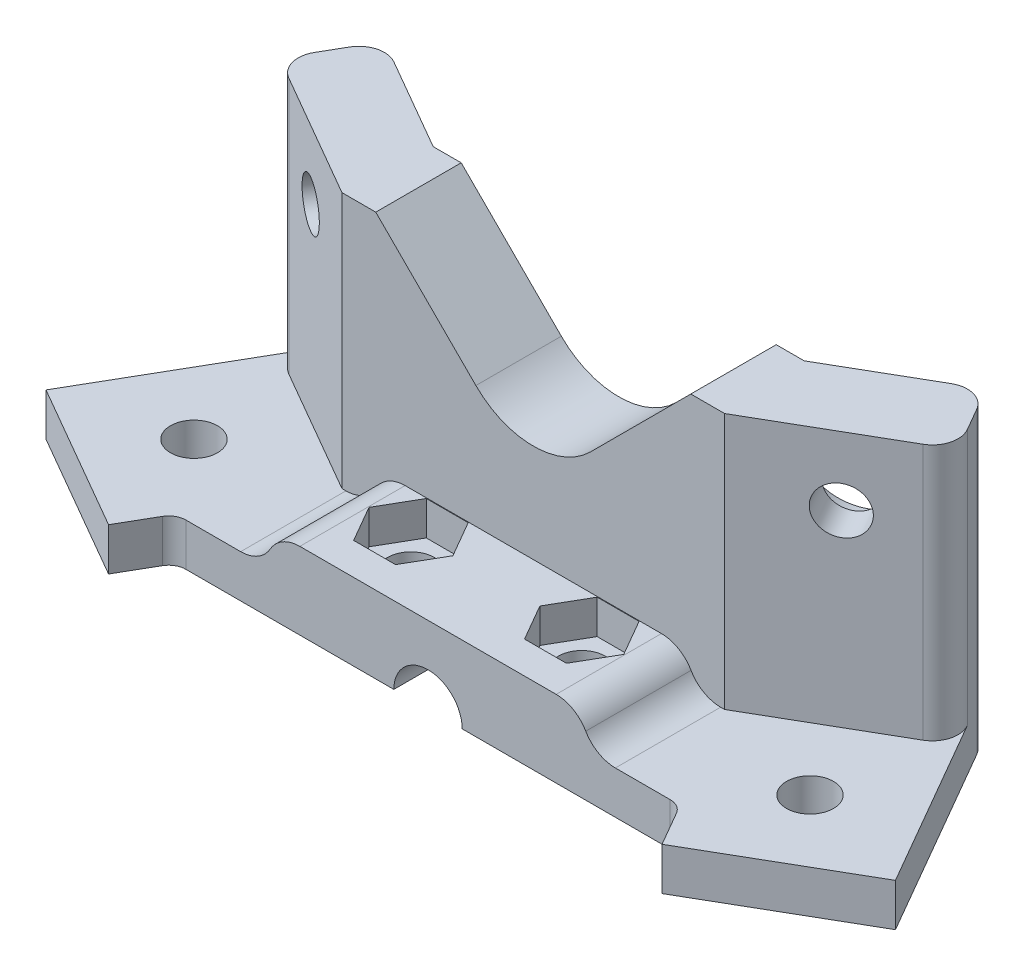
from build123d import *

# Parameters (mm, degrees)
SKETCH1_R                = 2.75
BOSS_EXTRUDE1_DEPTH      = 5
BOSS_EXTRUDE2_DEPTH      = 30
BOSS_EXTRUDE2_DEPTH_BACK = 5
BOSS_EXTRUDE3_DEPTH      = 12.320508
SKETCH5_R                = 4
CUT_EXTRUDE1_DEPTH       = 28.320508076
SKETCH7_R                = 2.75
CUT_EXTRUDE3_DEPTH       = 51.510942144
CUT_EXTRUDE4_START       = -4
SKETCH8_R                = 6
CUT_EXTRUDE4_DEPTH       = 47.510942144
SKETCH9_R                = 2.75
CUT_EXTRUDE5_DEPTH       = 10
CUT_EXTRUDE6_DEPTH       = 4
FILLET2_R                = 3


with BuildPart() as part:
    # Sketch1 → Boss-Extrude1 (new body)
    with BuildSketch(Plane(origin=(0, 0, 0), x_dir=(1, 0, 0), z_dir=(0, 1, 0))):
        with BuildLine():
            Line((-39.711904038, 0), (39.711904038, 0))
            Line((39.711904038, 0), (49.711904038, -17.320508076))
            Line((49.711904038, -17.320508076), (32.391395962, -27.320508076))
            Line((32.391395962, -27.320508076), (30.081994885, -23.320508076))
            ThreePointArc((30.081994885, -23.320508076), (29.349944078, -22.588457268), (28.349944078, -22.320508076))
            Line((28.349944078, -22.320508076), (-28.349944078, -22.320508076))
            ThreePointArc((-28.349944078, -22.320508076), (-29.349944078, -22.588457268), (-30.081994885, -23.320508076))
            Line((-30.081994885, -23.320508076), (-32.391395962, -27.320508076))
            Line((-32.391395962, -27.320508076), (-49.711904038, -17.320508076))
            Line((-49.711904038, -17.320508076), (-39.711904038, 0))
        make_face()
        with Locations(Location((-36.05165, -13.660254038, 0), (0, 0, 270))):  # turned: the seam where the file's is
            Circle(SKETCH1_R, mode=Mode.SUBTRACT)
        with Locations(Location((36.05165, -13.660254038, 0), (0, 0, 270))):  # turned: the seam where the file's is
            Circle(SKETCH1_R, mode=Mode.SUBTRACT)
    extrude(amount=BOSS_EXTRUDE1_DEPTH)

    # Sketch2 → Boss-Extrude2 (add, two sides)
    with BuildSketch(Plane(origin=(0, 5, 0), x_dir=(1, 0, 0), z_dir=(0, 1, 0))) as boss_extrude2_sk:
        with BuildLine():
            Line((-39.711904038, 0), (-22.391395962, -10))
            Line((-22.391395962, -10), (22.391395962, -10))
            Line((22.391395962, -10), (39.711904038, 0))
            Line((39.711904038, 0), (36.711904038, 5.196152423))
            ThreePointArc((36.711904038, 5.196152423), (34.890284962, 6.593929902), (32.613827826, 6.294228634))
            Line((32.613827826, 6.294228634), (21.711904038, 0))
            Line((21.711904038, 0), (-21.711904038, 0))
            Line((-21.711904038, 0), (-32.613827826, 6.294228634))
            ThreePointArc((-32.613827826, 6.294228634), (-34.890284962, 6.593929902), (-36.711904038, 5.196152423))
            Line((-36.711904038, 5.196152423), (-39.711904038, 0))
        make_face()
    extrude(amount=BOSS_EXTRUDE2_DEPTH)
    extrude(boss_extrude2_sk.sketch, amount=-BOSS_EXTRUDE2_DEPTH_BACK)

    # Sketch4 → Boss-Extrude3 (add)
    with BuildSketch(Plane.XY.offset(10)):
        with BuildLine():
            Line((-15, 9), (15, 9))
            ThreePointArc((15, 9), (17, 8.464101615), (18.464101615, 7))
            ThreePointArc((18.464101615, 7), (19.92820323, 5.535898385), (21.92820323, 5))
            Line((21.92820323, 5), (-21.92820323, 5))
            ThreePointArc((-21.92820323, 5), (-19.92820323, 5.535898385), (-18.464101615, 7))
            ThreePointArc((-18.464101615, 7), (-17, 8.464101615), (-15, 9))
        make_face()
    extrude(amount=BOSS_EXTRUDE3_DEPTH)

    # Sketch5 → Cut-Extrude1 (cut, through all)
    with BuildSketch(Plane(origin=(0, 0, 0), x_dir=(-1, 0, 0), z_dir=(0, 0, -1))):
        Circle(SKETCH5_R)
        with BuildLine():
            Line((-6.717514421, 23.282485579), (-18.435028843, 35))
            Line((-18.435028843, 35), (18.435028843, 35))
            Line((18.435028843, 35), (6.717514421, 23.282485579))
            ThreePointArc((6.717514421, 23.282485579), (0, 20.5), (-6.717514421, 23.282485579))
        make_face()
    extrude(amount=-CUT_EXTRUDE1_DEPTH, mode=Mode.SUBTRACT)

    # Sketch7 → Cut-Extrude3 (cut, through all)
    with BuildSketch(Plane(origin=(9.927976009, 0, 17.195758865), x_dir=(0.866025404, 0, -0.5), z_dir=(0.5, 0, 0.866025404))):
        with Locations((24.391517729, 27)):
            Circle(SKETCH7_R)
    cut_extrude3 = extrude(amount=-CUT_EXTRUDE3_DEPTH, mode=Mode.SUBTRACT)

    # Sketch8 → Cut-Extrude4 (cut, through all)
    with BuildSketch(Plane(origin=(9.927976009, 0, 17.195758865), x_dir=(0.866025404, 0, -0.5), z_dir=(0.5, 0, 0.866025404)).offset(CUT_EXTRUDE4_START)):
        with Locations((24.391517729, 27)):
            Circle(SKETCH8_R)
    cut_extrude4 = extrude(amount=-CUT_EXTRUDE4_DEPTH, mode=Mode.SUBTRACT)

    # Mirror1: Cut-Extrude3, Cut-Extrude4 across plane
    add(cut_extrude3.mirror(Plane(origin=(0, 0, 0), x_dir=(0, 0, 1), z_dir=(1, 0, 0))), mode=Mode.SUBTRACT)
    add(cut_extrude4.mirror(Plane(origin=(0, 0, 0), x_dir=(0, 0, 1), z_dir=(1, 0, 0))), mode=Mode.SUBTRACT)

    # Sketch9 → Cut-Extrude5 (cut, through all)
    with BuildSketch(Plane(origin=(0, 9, 0), x_dir=(1, 0, 0), z_dir=(0, 1, 0))):
        with Locations(Location((-10, -14.32050808, 0), (0, 0, 180))):  # turned: the seam where the file's is
            Circle(SKETCH9_R)
        with Locations(Location((10, -14.32050808, 0), (0, 0, 180))):  # turned: the seam where the file's is
            Circle(SKETCH9_R)
    extrude(amount=-CUT_EXTRUDE5_DEPTH, mode=Mode.SUBTRACT)

    # Sketch10 → Cut-Extrude6 (cut)
    with BuildSketch(Plane(origin=(0, 9, 0), x_dir=(1, 0, 0), z_dir=(0, 1, 0))):
        Polygon((-5.092522712, -14.32050808), (-7.546261356, -10.07050808), (-12.453738644, -10.07050808), (-14.907477288, -14.32050808), (-12.453738644, -18.57050808), (-7.546261356, -18.57050808), align=None)
        Polygon((5.092522712, -14.32050808), (7.546261356, -18.57050808), (12.453738644, -18.57050808), (14.907477288, -14.32050808), (12.453738644, -10.07050808), (7.546261356, -10.07050808), align=None)
    extrude(amount=-CUT_EXTRUDE6_DEPTH, mode=Mode.SUBTRACT)

    # Fillet2
    fillet2_edges = [part.edges().sort_by_distance(p)[0] for p in [
        (39.711904038, 20, 0),
        (-39.711904038, 20, 0),
    ]]
    fillet(fillet2_edges, radius=FILLET2_R)


solid = part.part
